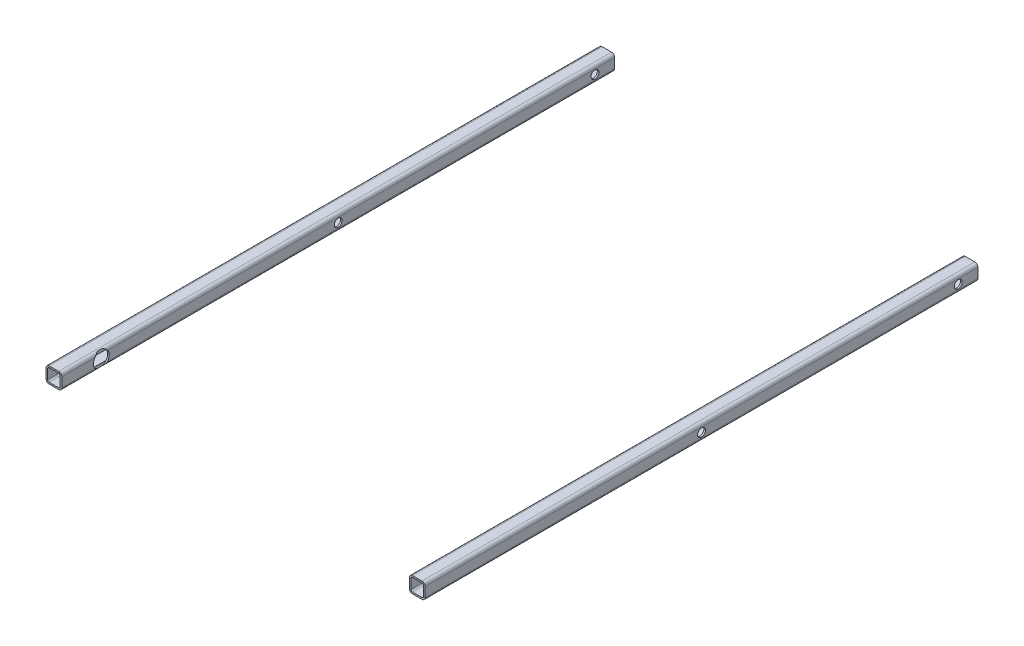
from build123d import *

# Parameters (mm, degrees)
SQUARE_TUBE_CONFIGURED_20_X_20_X_2_1_DEPTH   = 700
SQUARE_TUBE_CONFIGURED_20_X_20_X_2_1_2_DEPTH = 700
SKETCH15_R                                   = 5
CUT_EXTRUDE1_DEPTH                           = 531.094331228
CUT_EXTRUDE1_DEPTH_BACK                      = 531.094331228
SKETCH18_R                                   = 5
CUT_EXTRUDE2_DEPTH                           = 644.583716388
CUT_EXTRUDE2_DEPTH_BACK                      = 644.583716388
SKETCH13_R                                   = 10
CUT_EXTRUDE3_DEPTH                           = 442
CUT_EXTRUDE3_DEPTH_BACK                      = 2


with BuildPart() as part:
    # Sketch17 → Square tube - configured 20 X 20 X 2(1) (new body)
    with BuildSketch(Plane(origin=(-270, 0, -450), x_dir=(1, 0, 0), z_dir=(0, 0, 1))):
        with BuildLine():
            Line((-6, -10), (6, -10))
            ThreePointArc((6, -10), (8.828427125, -8.828427125), (10, -6))
            Line((10, -6), (10, 6))
            ThreePointArc((10, 6), (8.828427125, 8.828427125), (6, 10))
            Line((6, 10), (-6, 10))
            ThreePointArc((-6, 10), (-8.828427125, 8.828427125), (-10, 6))
            Line((-10, 6), (-10, -6))
            ThreePointArc((-10, -6), (-8.828427125, -8.828427125), (-6, -10))
        make_face()
        with BuildLine():
            Line((-6, -8), (6, -8))
            ThreePointArc((6, -8), (7.414213562, -7.414213562), (8, -6))
            Line((8, -6), (8, 6))
            ThreePointArc((8, 6), (7.414213562, 7.414213562), (6, 8))
            Line((6, 8), (-6, 8))
            ThreePointArc((-6, 8), (-7.414213562, 7.414213562), (-8, 6))
            Line((-8, 6), (-8, -6))
            ThreePointArc((-8, -6), (-7.414213562, -7.414213562), (-6, -8))
        make_face(mode=Mode.SUBTRACT)
    extrude(amount=SQUARE_TUBE_CONFIGURED_20_X_20_X_2_1_DEPTH)


with BuildPart() as body_2:
    # Sketch17 on segment 2 (carried to segment 2) → Square tube - configured 20 X 20 X 2_1 2 (new body)
    with BuildSketch(Plane(origin=(190, 0, -450), x_dir=(1, 0, 0), z_dir=(0, 0, 1))):
        with BuildLine():
            Line((-6, -10), (6, -10))
            ThreePointArc((6, -10), (8.828427125, -8.828427125), (10, -6))
            Line((10, -6), (10, 6))
            ThreePointArc((10, 6), (8.828427125, 8.828427125), (6, 10))
            Line((6, 10), (-6, 10))
            ThreePointArc((-6, 10), (-8.828427125, 8.828427125), (-10, 6))
            Line((-10, 6), (-10, -6))
            ThreePointArc((-10, -6), (-8.828427125, -8.828427125), (-6, -10))
        make_face()
        with BuildLine():
            Line((-6, -8), (6, -8))
            ThreePointArc((6, -8), (7.414213562, -7.414213562), (8, -6))
            Line((8, -6), (8, 6))
            ThreePointArc((8, 6), (7.414213562, 7.414213562), (6, 8))
            Line((6, 8), (-6, 8))
            ThreePointArc((-6, 8), (-7.414213562, 7.414213562), (-8, 6))
            Line((-8, 6), (-8, -6))
            ThreePointArc((-8, -6), (-7.414213562, -7.414213562), (-6, -8))
        make_face(mode=Mode.SUBTRACT)
    extrude(amount=SQUARE_TUBE_CONFIGURED_20_X_20_X_2_1_2_DEPTH)


with BuildPart() as cut_extrude1_tool:
    # Sketch15 → Cut-Extrude1 (new, two sides)
    with BuildSketch(Plane(origin=(0, 0, 0), x_dir=(0, 0, -1), z_dir=(1, 0, 0))) as cut_extrude1_sk:
        with Locations((100, 0)):
            Circle(SKETCH15_R)
    extrude(amount=CUT_EXTRUDE1_DEPTH)
    extrude(cut_extrude1_sk.sketch, amount=-CUT_EXTRUDE1_DEPTH_BACK)


with BuildPart() as part_1:
    add(part.part)

    # Cut-Extrude1: cut by cut_extrude1_tool
    add(cut_extrude1_tool.part, mode=Mode.SUBTRACT)


with BuildPart() as body_2_1:
    add(body_2.part)

    # Cut-Extrude1: cut by cut_extrude1_tool
    add(cut_extrude1_tool.part, mode=Mode.SUBTRACT)


with BuildPart() as cut_extrude2_tool:
    # Sketch18 → Cut-Extrude2 (new, two sides)
    with BuildSketch(Plane.ZY.offset(-180)) as cut_extrude2_sk:
        with Locations((-425, 0)):
            Circle(SKETCH18_R)
    extrude(amount=CUT_EXTRUDE2_DEPTH)
    extrude(cut_extrude2_sk.sketch, amount=-CUT_EXTRUDE2_DEPTH_BACK)


with BuildPart() as part_2:
    add(part_1.part)

    # Cut-Extrude2: cut by cut_extrude2_tool
    add(cut_extrude2_tool.part, mode=Mode.SUBTRACT)


with BuildPart() as body_2_2:
    add(body_2_1.part)

    # Cut-Extrude2: cut by cut_extrude2_tool
    add(cut_extrude2_tool.part, mode=Mode.SUBTRACT)


with BuildPart() as cut_extrude3_tool:
    # Sketch13 → Cut-Extrude3 (new, two sides)
    with BuildSketch(Plane.ZY.offset(-180)) as cut_extrude3_sk:
        with Locations((200, 0)):
            Circle(SKETCH13_R)
    extrude(amount=CUT_EXTRUDE3_DEPTH)
    extrude(cut_extrude3_sk.sketch, amount=-CUT_EXTRUDE3_DEPTH_BACK)


with BuildPart() as part_3:
    add(part_2.part)

    # Cut-Extrude3: cut by cut_extrude3_tool
    add(cut_extrude3_tool.part, mode=Mode.SUBTRACT)


with BuildPart() as body_2_3:
    add(body_2_2.part)

    # Cut-Extrude3: cut by cut_extrude3_tool
    add(cut_extrude3_tool.part, mode=Mode.SUBTRACT)


solid = Compound([part_3.part, body_2_3.part])
